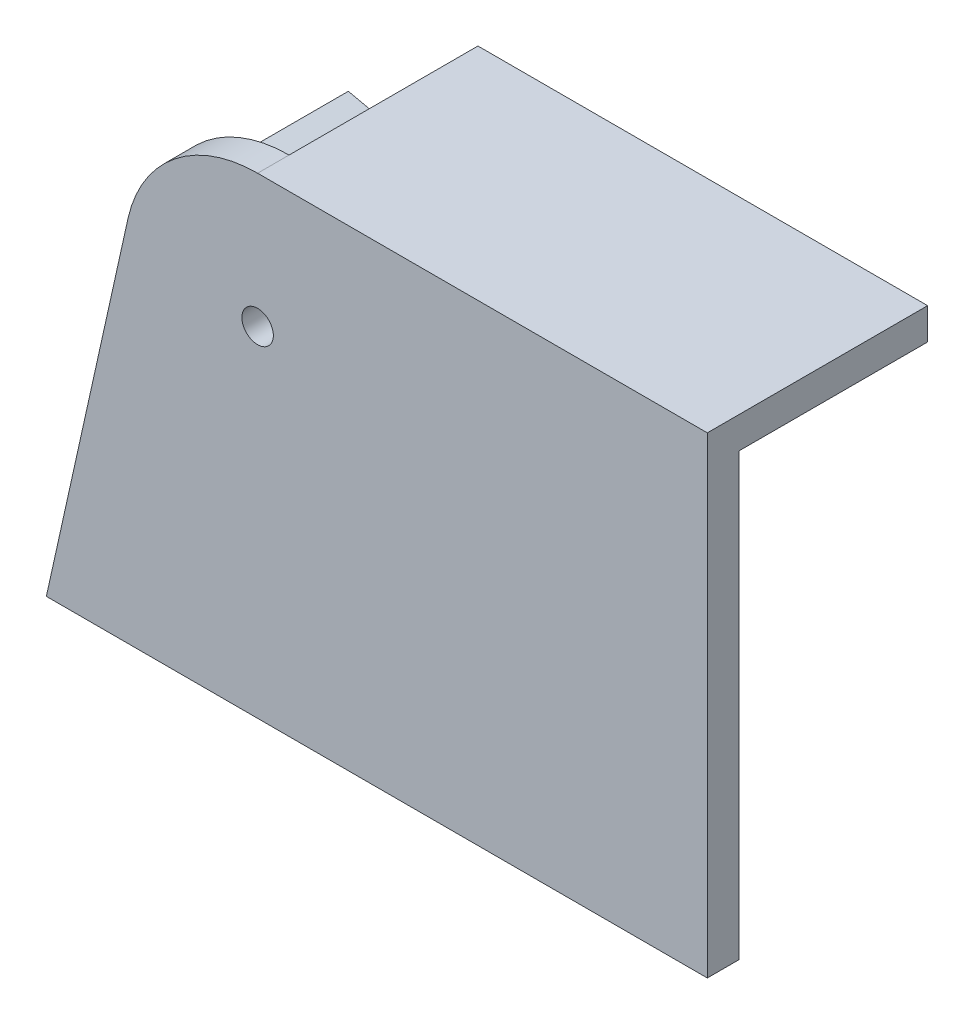
from build123d import *

# Parameters (mm, degrees)
SKETCH1_R           = 2.5
BOSS_EXTRUDE1_DEPTH = 5
SKETCH2_W           = 71.44
SKETCH2_H           = 5
BOSS_EXTRUDE2_DEPTH = 35


with BuildPart() as part:
    # Sketch1 → Boss-Extrude1 (new body)
    with BuildSketch(Plane.XY):
        with BuildLine():
            Line((-92.029607558, 58.476854566), (-105, 0))
            Line((-105, 0), (0, 0))
            Line((0, 0), (0, 75))
            Line((0, 75), (-71.44, 75))
            ThreePointArc((-71.44, 75), (-84.639870022, 70.358450729), (-92.029607558, 58.476854566))
        make_face()
        with Locations((-71.44, 53.91)):
            Circle(SKETCH1_R, mode=Mode.SUBTRACT)
    extrude(amount=BOSS_EXTRUDE1_DEPTH)

    # Sketch2 → Boss-Extrude2 (add)
    with BuildSketch(Plane.XY.offset(5)):
        Polygon((-105, 0), (-92.029607558, 58.476854566), (-87.14824019, 57.39414841), (-99.878484221, 0), align=None)
        with Locations((-35.72, 72.5)):
            Rectangle(SKETCH2_W, SKETCH2_H)
    extrude(amount=-BOSS_EXTRUDE2_DEPTH)


solid = part.part
